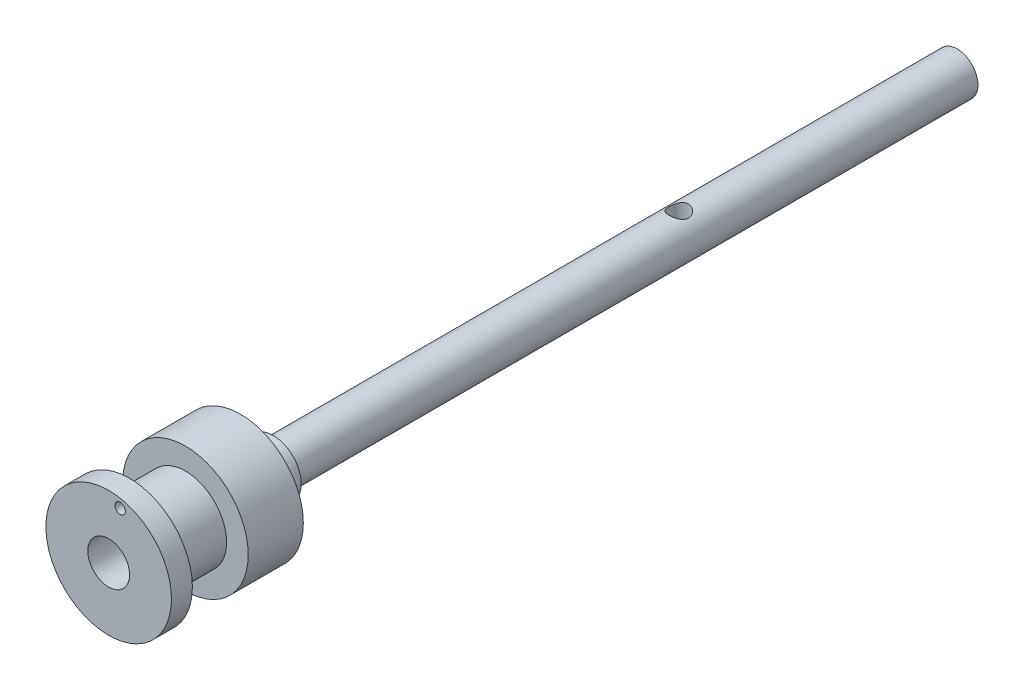
from build123d import *

# Parameters (mm, degrees)
SKETCH1_R               = 3
BOSS_EXTRUDE1_DEPTH     = 98
SKETCH2_R               = 4
BOSS_EXTRUDE2_DEPTH     = 4.7
SKETCH3_R               = 9
BOSS_EXTRUDE3_DEPTH     = 7.9
SKETCH4_R               = 5.9
BOSS_EXTRUDE4_DEPTH     = 8
SKETCH5_R               = 9
BOSS_EXTRUDE5_DEPTH     = 3
CUT_EXTRUDE1_DEPTH      = 82
CUT_EXTRUDE1_DEPTH_BACK = 82
SKETCH6_R               = 1.4
CUT_EXTRUDE2_START      = -9
SKETCH7_R               = 3
SKETCH7_R_2             = 0.75
CUT_EXTRUDE2_DEPTH      = 9


with BuildPart() as part:
    # Sketch1 → Boss-Extrude1 (new body)
    with BuildSketch(Plane.XY):
        Circle(SKETCH1_R)
    extrude(amount=BOSS_EXTRUDE1_DEPTH)

    # Sketch2 → Boss-Extrude2 (add)
    with BuildSketch(Plane.XY.offset(98)):
        Circle(SKETCH2_R)
    extrude(amount=BOSS_EXTRUDE2_DEPTH)

    # Sketch3 → Boss-Extrude3 (add)
    with BuildSketch(Plane.XY.offset(102.7)):
        Circle(SKETCH3_R)
    extrude(amount=BOSS_EXTRUDE3_DEPTH)

    # Sketch4 → Boss-Extrude4 (add)
    with BuildSketch(Plane.XY.offset(110.6)):
        Circle(SKETCH4_R)
    extrude(amount=BOSS_EXTRUDE4_DEPTH)

    # Sketch5 → Boss-Extrude5 (add)
    with BuildSketch(Plane.XY.offset(118.6)):
        Circle(SKETCH5_R)
    extrude(amount=BOSS_EXTRUDE5_DEPTH)

    # Sketch6 → Cut-Extrude1 (cut, two sides: drawn at the far end of the back side and taken through both)
    with BuildSketch(Plane(origin=(0, 0, 0), x_dir=(1, 0, 0), z_dir=(0, 1, 0)).offset(-CUT_EXTRUDE1_DEPTH_BACK)):
        with Locations((0, -39.9)):
            Circle(SKETCH6_R)
    extrude(amount=CUT_EXTRUDE1_DEPTH + CUT_EXTRUDE1_DEPTH_BACK, mode=Mode.SUBTRACT)

    # Sketch7 → Cut-Extrude2 (cut)
    with BuildSketch(Plane.XY.offset(121.6).offset(CUT_EXTRUDE2_START)):
        Circle(SKETCH7_R)
        with Locations((1.637751338, 7.588247864)):
            Circle(SKETCH7_R_2)
    extrude(amount=CUT_EXTRUDE2_DEPTH, mode=Mode.SUBTRACT)


solid = part.part
